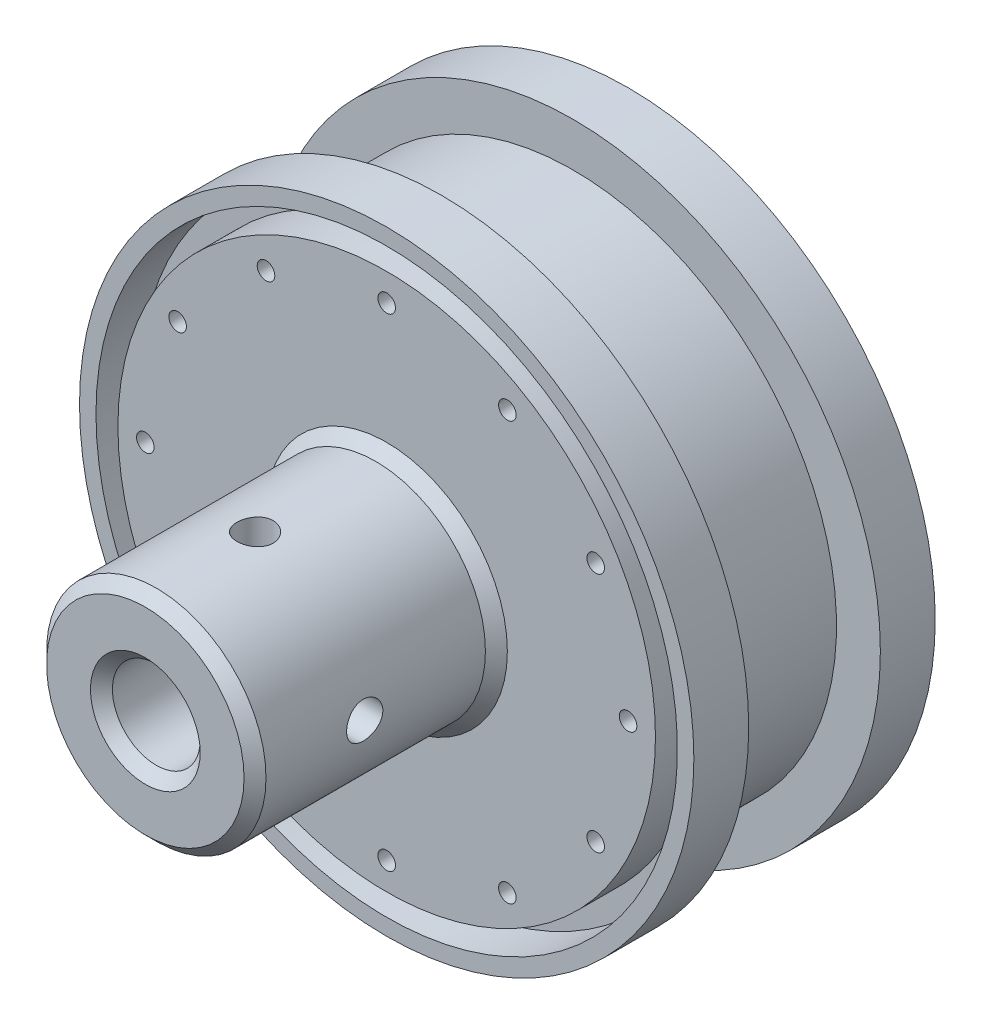
from build123d import *

# Parameters (mm, degrees)
SKETCH1_R                                           = 28
BOSS_EXTRUDE1_DEPTH                                 = 22
SKETCH2_R                                           = 10
BOSS_EXTRUDE2_DEPTH                                 = 22
SKETCH3_R                                           = 20
CUT_EXTRUDE1_DEPTH                                  = 16
CHAMFER1_SIZE                                       = 4
SKETCH4_R                                           = 4
CUT_EXTRUDE2_DEPTH                                  = 20
CBORE_FOR_M3_HEX_SOCKET_HEAD_CAP_SCREW1_D           = 3.4
CBORE_FOR_M3_HEX_SOCKET_HEAD_CAP_SCREW1_CBORE_D     = 6.5
CBORE_FOR_M3_HEX_SOCKET_HEAD_CAP_SCREW1_CBORE_DEPTH = 3.4
SKETCH7_R                                           = 26.5
SKETCH7_R_2                                         = 24.5
CUT_EXTRUDE3_DEPTH                                  = 4
M2_TAPPED_HOLE1_AT_2_COUNT                          = 2
M2_TAPPED_HOLE1_AT_2_PITCH                          = 11.388037985
M2_TAPPED_HOLE1_AT_3_COUNT                          = 2
M2_TAPPED_HOLE1_AT_3_PITCH                          = 22
M2_TAPPED_HOLE1_AT_4_COUNT                          = 2
M2_TAPPED_HOLE1_AT_4_PITCH                          = 31.112698372
M2_TAPPED_HOLE1_AT_5_COUNT                          = 2
M2_TAPPED_HOLE1_AT_5_PITCH                          = 38.105117767
M2_TAPPED_HOLE1_AT_6_COUNT                          = 2
M2_TAPPED_HOLE1_AT_6_PITCH                          = 42.500736357
M2_TAPPED_HOLE1_AT_7_COUNT                          = 2
M2_TAPPED_HOLE1_AT_7_PITCH                          = 44
M2_TAPPED_HOLE1_AT_8_COUNT                          = 2
M2_TAPPED_HOLE1_AT_8_PITCH                          = 42.500736357
M2_TAPPED_HOLE1_AT_9_COUNT                          = 2
M2_TAPPED_HOLE1_AT_9_PITCH                          = 38.105117767
M2_TAPPED_HOLE1_AT_10_COUNT                         = 2
M2_TAPPED_HOLE1_AT_10_PITCH                         = 31.112698372
M2_TAPPED_HOLE1_AT_11_COUNT                         = 2
M2_TAPPED_HOLE1_AT_11_PITCH                         = 22
M2_TAPPED_HOLE1_AT_12_COUNT                         = 2
M2_TAPPED_HOLE1_AT_12_PITCH                         = 11.388037985
SKETCH10_R                                          = 28
SKETCH10_R_2                                        = 24
CUT_EXTRUDE5_DEPTH                                  = 6
CUT_EXTRUDE5_DEPTH_BACK                             = 6
CHAMFER2_SIZE                                       = 1
M4_TAPPED_HOLE1_REACH                               = 60.172
M4_TAPPED_HOLE1_BORE_R                              = 1.65
CIRPATTERN1_COUNT                                   = 2
CIRPATTERN1_ANGLE                                   = 90


with BuildPart() as part:
    # Sketch1 → Boss-Extrude1 (new body)
    with BuildSketch(Plane.XY):
        Circle(SKETCH1_R)
    extrude(amount=BOSS_EXTRUDE1_DEPTH)

    # Sketch2 → Boss-Extrude2 (add)
    with BuildSketch(Plane.XY.offset(22)):
        Circle(SKETCH2_R)
    extrude(amount=BOSS_EXTRUDE2_DEPTH)

    # Sketch3 → Cut-Extrude1 (cut)
    with BuildSketch(Plane(origin=(0, 0, 0), x_dir=(-1, 0, 0), z_dir=(0, 0, -1))):
        Circle(SKETCH3_R)
    extrude(amount=-CUT_EXTRUDE1_DEPTH, mode=Mode.SUBTRACT)

    # Chamfer1
    chamfer1_edges = [part.edges().sort_by_distance(p)[0] for p in [
        (20, 0, 16),
    ]]
    chamfer(chamfer1_edges, length=CHAMFER1_SIZE)

    # Sketch4 → Cut-Extrude2 (cut)
    with BuildSketch(Plane.XY.offset(44)):
        Circle(SKETCH4_R)
    extrude(amount=-CUT_EXTRUDE2_DEPTH, mode=Mode.SUBTRACT)

    # CBORE for M3 Hex Socket Head Cap Screw1 (through all)
    with Locations(Plane(origin=(0, 0, 16), x_dir=(-1, 0, 0), z_dir=(0, 0, -1))):
        with Locations((0, 0)):
            CounterBoreHole(CBORE_FOR_M3_HEX_SOCKET_HEAD_CAP_SCREW1_D / 2, CBORE_FOR_M3_HEX_SOCKET_HEAD_CAP_SCREW1_CBORE_D / 2, CBORE_FOR_M3_HEX_SOCKET_HEAD_CAP_SCREW1_CBORE_DEPTH)

    # Sketch7 → Cut-Extrude3 (cut)
    with BuildSketch(Plane(origin=(0, 0, 0), x_dir=(-1, 0, 0), z_dir=(0, 0, -1))):
        Circle(SKETCH7_R)
        Circle(SKETCH7_R_2, mode=Mode.SUBTRACT)
    cut_extrude3 = extrude(amount=-CUT_EXTRUDE3_DEPTH, mode=Mode.SUBTRACT)

    # Mirror1: Cut-Extrude3 across plane
    add(cut_extrude3.mirror(Plane(origin=(0, 0, 11), x_dir=(1, 0, 0), z_dir=(0, 0, -1))), mode=Mode.SUBTRACT)

    # Sketch9 → M2 Tapped Hole1 (revolve, cut)
    with BuildSketch(Plane(origin=(0, 22, 0), x_dir=(0, 1, 0), z_dir=(1, 0, 0))):
        Polygon((0, 0), (0, 8.480688495), (0.8, 8), (0.8, 0), align=None)
    m2_tapped_hole1 = revolve(axis=Axis((0, 22, -6.35), (0, 0, 1)), mode=Mode.SUBTRACT)

    # M2 Tapped Hole1 at 2: M2 Tapped Hole1 ×2
    with Locations(*[Vector(-0.9659258262891051, -0.2588190451023836, 0) * (i * M2_TAPPED_HOLE1_AT_2_PITCH) for i in range(1, M2_TAPPED_HOLE1_AT_2_COUNT)]):
        add(m2_tapped_hole1, mode=Mode.SUBTRACT)

    # M2 Tapped Hole1 at 3: M2 Tapped Hole1 ×2
    with Locations(*[Vector(-0.8660254037845097, -0.4999999999998771, 0) * (i * M2_TAPPED_HOLE1_AT_3_PITCH) for i in range(1, M2_TAPPED_HOLE1_AT_3_COUNT)]):
        add(m2_tapped_hole1, mode=Mode.SUBTRACT)

    # M2 Tapped Hole1 at 4: M2 Tapped Hole1 ×2
    with Locations(*[Vector(-0.7071067811866479, -0.7071067811864472, 0) * (i * M2_TAPPED_HOLE1_AT_4_PITCH) for i in range(1, M2_TAPPED_HOLE1_AT_4_COUNT)]):
        add(m2_tapped_hole1, mode=Mode.SUBTRACT)

    # M2 Tapped Hole1 at 5: M2 Tapped Hole1 ×2
    with Locations(*[Vector(-0.500000000000123, -0.8660254037843677, 0) * (i * M2_TAPPED_HOLE1_AT_5_PITCH) for i in range(1, M2_TAPPED_HOLE1_AT_5_COUNT)]):
        add(m2_tapped_hole1, mode=Mode.SUBTRACT)

    # M2 Tapped Hole1 at 6: M2 Tapped Hole1 ×2
    with Locations(*[Vector(-0.2588190451026581, -0.9659258262890316, 0) * (i * M2_TAPPED_HOLE1_AT_6_PITCH) for i in range(1, M2_TAPPED_HOLE1_AT_6_COUNT)]):
        add(m2_tapped_hole1, mode=Mode.SUBTRACT)

    # M2 Tapped Hole1 at 7: M2 Tapped Hole1 ×2
    with Locations(*[(0, -i * M2_TAPPED_HOLE1_AT_7_PITCH, 0) for i in range(1, M2_TAPPED_HOLE1_AT_7_COUNT)]):
        add(m2_tapped_hole1, mode=Mode.SUBTRACT)

    # M2 Tapped Hole1 at 8: M2 Tapped Hole1 ×2
    with Locations(*[Vector(0.25881904510238346, -0.9659258262891051, 0) * (i * M2_TAPPED_HOLE1_AT_8_PITCH) for i in range(1, M2_TAPPED_HOLE1_AT_8_COUNT)]):
        add(m2_tapped_hole1, mode=Mode.SUBTRACT)

    # M2 Tapped Hole1 at 9: M2 Tapped Hole1 ×2
    with Locations(*[Vector(0.4999999999998768, -0.8660254037845098, 0) * (i * M2_TAPPED_HOLE1_AT_9_PITCH) for i in range(1, M2_TAPPED_HOLE1_AT_9_COUNT)]):
        add(m2_tapped_hole1, mode=Mode.SUBTRACT)

    # M2 Tapped Hole1 at 10: M2 Tapped Hole1 ×2
    with Locations(*[Vector(0.7071067811864471, -0.7071067811866479, 0) * (i * M2_TAPPED_HOLE1_AT_10_PITCH) for i in range(1, M2_TAPPED_HOLE1_AT_10_COUNT)]):
        add(m2_tapped_hole1, mode=Mode.SUBTRACT)

    # M2 Tapped Hole1 at 11: M2 Tapped Hole1 ×2
    with Locations(*[Vector(0.8660254037843675, -0.5000000000001233, 0) * (i * M2_TAPPED_HOLE1_AT_11_PITCH) for i in range(1, M2_TAPPED_HOLE1_AT_11_COUNT)]):
        add(m2_tapped_hole1, mode=Mode.SUBTRACT)

    # M2 Tapped Hole1 at 12: M2 Tapped Hole1 ×2
    with Locations(*[Vector(0.9659258262890317, -0.2588190451026578, 0) * (i * M2_TAPPED_HOLE1_AT_12_PITCH) for i in range(1, M2_TAPPED_HOLE1_AT_12_COUNT)]):
        add(m2_tapped_hole1, mode=Mode.SUBTRACT)

    # Sketch10 → Cut-Extrude5 (cut, two sides)
    with BuildSketch(Plane(origin=(0, 0, 11), x_dir=(-1, 0, 0), z_dir=(0, 0, -1))) as cut_extrude5_sk:
        Circle(SKETCH10_R)
        Circle(SKETCH10_R_2, mode=Mode.SUBTRACT)
    extrude(amount=CUT_EXTRUDE5_DEPTH, mode=Mode.SUBTRACT)
    extrude(cut_extrude5_sk.sketch, amount=-CUT_EXTRUDE5_DEPTH_BACK, mode=Mode.SUBTRACT)

    # Mirror2: M2 Tapped Hole1 across plane
    add(m2_tapped_hole1.mirror(Plane(origin=(0, 0, 11), x_dir=(1, 0, 0), z_dir=(0, 0, -1))), mode=Mode.SUBTRACT)

    # Mirror2 copy 1 sketch → Mirror2 copy 1 (revolve, cut)
    with BuildSketch(Plane(origin=(-11, 19.052558883, 22), x_dir=(0, 1, 0), z_dir=(1, 0, 0))):
        Polygon((0, 0), (0, -8.480688495), (0.8, -8), (0.8, 0), align=None)
    revolve(axis=Axis((-11, 19.052558883, 28.35), (0, 0, 1)), mode=Mode.SUBTRACT)

    # Mirror2 copy 2 sketch → Mirror2 copy 2 (revolve, cut)
    with BuildSketch(Plane(origin=(-19.052558883, 11, 22), x_dir=(0, 1, 0), z_dir=(1, 0, 0))):
        Polygon((0, 0), (0, -8.480688495), (0.8, -8), (0.8, 0), align=None)
    revolve(axis=Axis((-19.052558883, 11, 28.35), (0, 0, 1)), mode=Mode.SUBTRACT)

    # Mirror2 copy 3 sketch → Mirror2 copy 3 (revolve, cut)
    with BuildSketch(Plane(origin=(-22, 0, 22), x_dir=(0, 1, 0), z_dir=(1, 0, 0))):
        Polygon((0, 0), (0, -8.480688495), (0.8, -8), (0.8, 0), align=None)
    revolve(axis=Axis((-22, 0, 28.35), (0, 0, 1)), mode=Mode.SUBTRACT)

    # Mirror2 copy 4 sketch → Mirror2 copy 4 (revolve, cut)
    with BuildSketch(Plane(origin=(-19.052558883, -11, 22), x_dir=(0, 1, 0), z_dir=(1, 0, 0))):
        Polygon((0, 0), (0, -8.480688495), (0.8, -8), (0.8, 0), align=None)
    revolve(axis=Axis((-19.052558883, -11, 28.35), (0, 0, 1)), mode=Mode.SUBTRACT)

    # Mirror2 copy 5 sketch → Mirror2 copy 5 (revolve, cut)
    with BuildSketch(Plane(origin=(-11, -19.052558883, 22), x_dir=(0, 1, 0), z_dir=(1, 0, 0))):
        Polygon((0, 0), (0, -8.480688495), (0.8, -8), (0.8, 0), align=None)
    revolve(axis=Axis((-11, -19.052558883, 28.35), (0, 0, 1)), mode=Mode.SUBTRACT)

    # Mirror2 copy 6 sketch → Mirror2 copy 6 (revolve, cut)
    with BuildSketch(Plane(origin=(0, -22, 22), x_dir=(0, 1, 0), z_dir=(1, 0, 0))):
        Polygon((0, 0), (0, -8.480688495), (0.8, -8), (0.8, 0), align=None)
    revolve(axis=Axis((0, -22, 28.35), (0, 0, 1)), mode=Mode.SUBTRACT)

    # Mirror2 copy 7 sketch → Mirror2 copy 7 (revolve, cut)
    with BuildSketch(Plane(origin=(11, -19.052558883, 22), x_dir=(0, 1, 0), z_dir=(1, 0, 0))):
        Polygon((0, 0), (0, -8.480688495), (0.8, -8), (0.8, 0), align=None)
    revolve(axis=Axis((11, -19.052558883, 28.35), (0, 0, 1)), mode=Mode.SUBTRACT)

    # Mirror2 copy 8 sketch → Mirror2 copy 8 (revolve, cut)
    with BuildSketch(Plane(origin=(19.052558883, -11, 22), x_dir=(0, 1, 0), z_dir=(1, 0, 0))):
        Polygon((0, 0), (0, -8.480688495), (0.8, -8), (0.8, 0), align=None)
    revolve(axis=Axis((19.052558883, -11, 28.35), (0, 0, 1)), mode=Mode.SUBTRACT)

    # Mirror2 copy 9 sketch → Mirror2 copy 9 (revolve, cut)
    with BuildSketch(Plane(origin=(22, 0, 22), x_dir=(0, 1, 0), z_dir=(1, 0, 0))):
        Polygon((0, 0), (0, -8.480688495), (0.8, -8), (0.8, 0), align=None)
    revolve(axis=Axis((22, 0, 28.35), (0, 0, 1)), mode=Mode.SUBTRACT)

    # Mirror2 copy 10 sketch → Mirror2 copy 10 (revolve, cut)
    with BuildSketch(Plane(origin=(19.052558883, 11, 22), x_dir=(0, 1, 0), z_dir=(1, 0, 0))):
        Polygon((0, 0), (0, -8.480688495), (0.8, -8), (0.8, 0), align=None)
    revolve(axis=Axis((19.052558883, 11, 28.35), (0, 0, 1)), mode=Mode.SUBTRACT)

    # Mirror2 copy 11 sketch → Mirror2 copy 11 (revolve, cut)
    with BuildSketch(Plane(origin=(11, 19.052558883, 22), x_dir=(0, 1, 0), z_dir=(1, 0, 0))):
        Polygon((0, 0), (0, -8.480688495), (0.8, -8), (0.8, 0), align=None)
    revolve(axis=Axis((11, 19.052558883, 28.35), (0, 0, 1)), mode=Mode.SUBTRACT)

    # Chamfer2
    chamfer2_edges = [part.edges().sort_by_distance(p)[0] for p in [
        (-4, 0, 44),
        (-10, 0, 22),
        (-10, 0, 44),
    ]]
    chamfer(chamfer2_edges, length=CHAMFER2_SIZE)

    # M4 Tapped Hole1 bore (on position points) → M4 Tapped Hole1 (cut, up to next)
    with BuildSketch(Plane(origin=(0, 10, 34), x_dir=(1, 0, 0), z_dir=(0, 1, 0)), mode=Mode.PRIVATE) as m4_tapped_hole1_sk1:
        Circle(M4_TAPPED_HOLE1_BORE_R)
    m4_tapped_hole1_tool1 = extrude(m4_tapped_hole1_sk1.sketch, amount=-M4_TAPPED_HOLE1_REACH, mode=Mode.PRIVATE) & part.part
    m4_tapped_hole1 = m4_tapped_hole1_tool1.solids().sort_by_distance((0, 10, 34))[0]
    add(m4_tapped_hole1, mode=Mode.SUBTRACT)

    # CirPattern1: M4 Tapped Hole1 ×2 about axis
    cirpattern1_axis = Axis((0, 0, 24), (0, 0, -1))
    for i in range(1, CIRPATTERN1_COUNT):
        add(m4_tapped_hole1.rotate(cirpattern1_axis, i * CIRPATTERN1_ANGLE / (CIRPATTERN1_COUNT - 1)), mode=Mode.SUBTRACT)


solid = part.part
